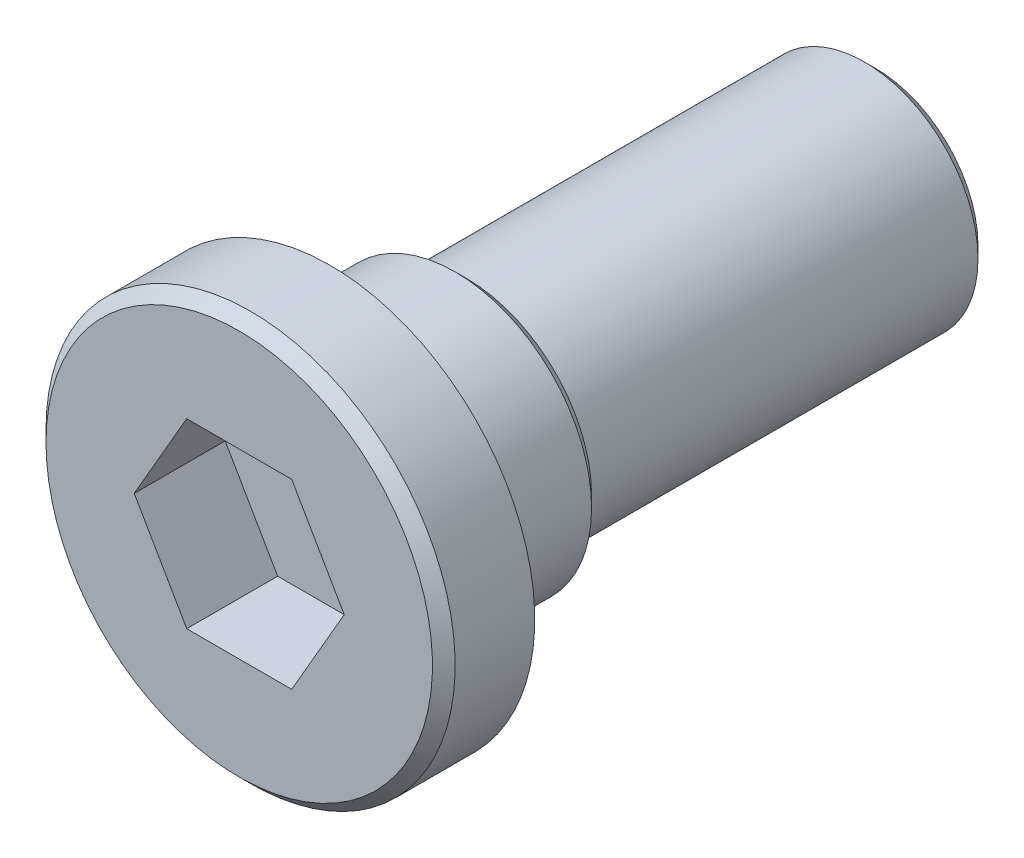
from build123d import *

# Parameters (mm, degrees)
CUT_EXTRUDE1_DEPTH = 1
CHAMFER1_SIZE      = 0.125


with BuildPart() as part:
    # Sketch1 → Revolve1 (revolve)
    with BuildSketch(Plane(origin=(0, 0, 0), x_dir=(1, 0, 0), z_dir=(0, 1, 0))):
        Polygon((0, 0), (0, 7), (1.25, 7), (1.25, 2.5), (1.5, 2.5), (1.5, 1), (2.25, 1), (2.25, 0), align=None)
    revolve(axis=Axis((0, 0, 0), (0, 0, 1)))

    # Sketch2 → Cut-Extrude1 (cut)
    with BuildSketch(Plane.XY):
        Polygon((1.154700538, 0), (0.577350269, 1), (-0.577350269, 1), (-1.154700538, 0), (-0.577350269, -1), (0.577350269, -1), align=None)
    extrude(amount=-CUT_EXTRUDE1_DEPTH, mode=Mode.SUBTRACT)

    # Chamfer1
    chamfer1_edges = [part.edges().sort_by_distance(p)[0] for p in [
        (-2.25, 0, 0),
        (-1.5, 0, -2.5),
        (-1.25, 0, -7),
    ]]
    chamfer(chamfer1_edges, length=CHAMFER1_SIZE)


solid = part.part
